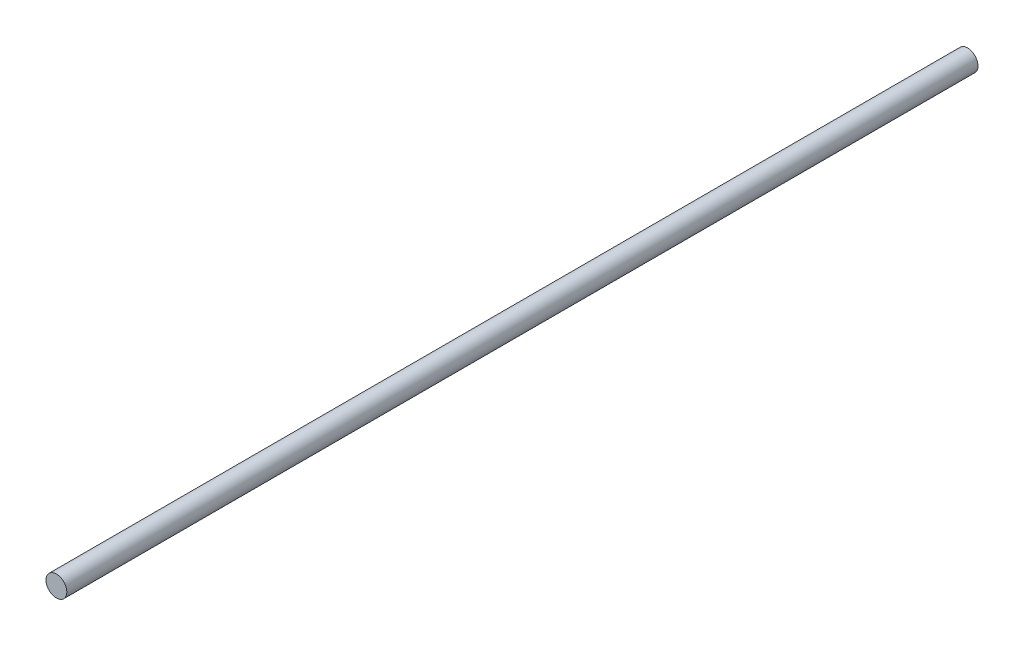
from build123d import *

# Parameters (mm, degrees)
CROQUIS1_R                   = 4
SALIENTE_EXTRUIR1_DEPTH      = 150
SALIENTE_EXTRUIR1_DEPTH_BACK = 200


with BuildPart() as part:
    # Croquis1 → Saliente-Extruir1 (new body, two sides)
    with BuildSketch(Plane.XY) as saliente_extruir1_sk:
        with Locations((29.932793709, -2.105552469)):
            Circle(CROQUIS1_R)
    extrude(amount=SALIENTE_EXTRUIR1_DEPTH)
    extrude(saliente_extruir1_sk.sketch, amount=-SALIENTE_EXTRUIR1_DEPTH_BACK)


solid = part.part
